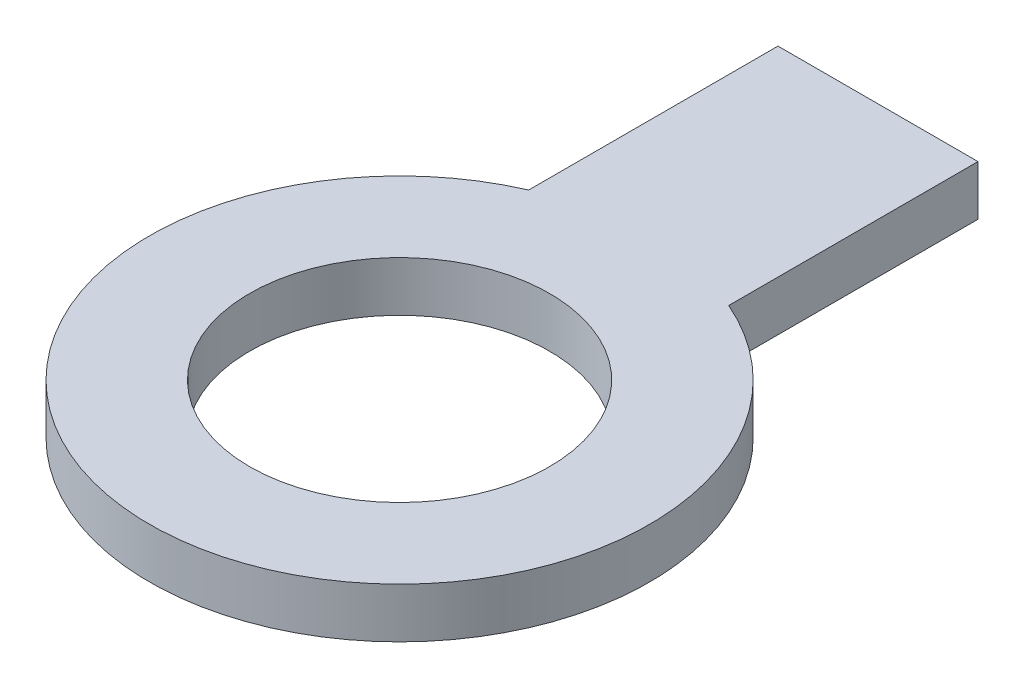
from build123d import *

# Parameters (mm, degrees)
SKETCH1_R           = 10
BOSS_EXTRUDE1_DEPTH = 2
SKETCH2_W           = 8
SKETCH2_H           = 9.97
BOSS_EXTRUDE2_DEPTH = 2
SKETCH3_R           = 6
CUT_EXTRUDE1_DEPTH  = 3


with BuildPart() as part:
    # Sketch1 → Boss-Extrude1 (new body)
    with BuildSketch(Plane(origin=(0, 0, 0), x_dir=(1, 0, 0), z_dir=(0, 1, 0))):
        Circle(SKETCH1_R)
    extrude(amount=-BOSS_EXTRUDE1_DEPTH)

    # Sketch2 → Boss-Extrude2 (add)
    with BuildSketch(Plane(origin=(0, 0, 0), x_dir=(1, 0, 0), z_dir=(0, 1, 0))):
        with Locations((0, 14.15015139)):
            Rectangle(SKETCH2_W, SKETCH2_H)
    extrude(amount=-BOSS_EXTRUDE2_DEPTH)

    # Sketch3 → Cut-Extrude1 (cut, through all)
    with BuildSketch(Plane(origin=(0, 0, 0), x_dir=(1, 0, 0), z_dir=(0, 1, 0))):
        Circle(SKETCH3_R)
    extrude(amount=-CUT_EXTRUDE1_DEPTH, mode=Mode.SUBTRACT)


solid = part.part
